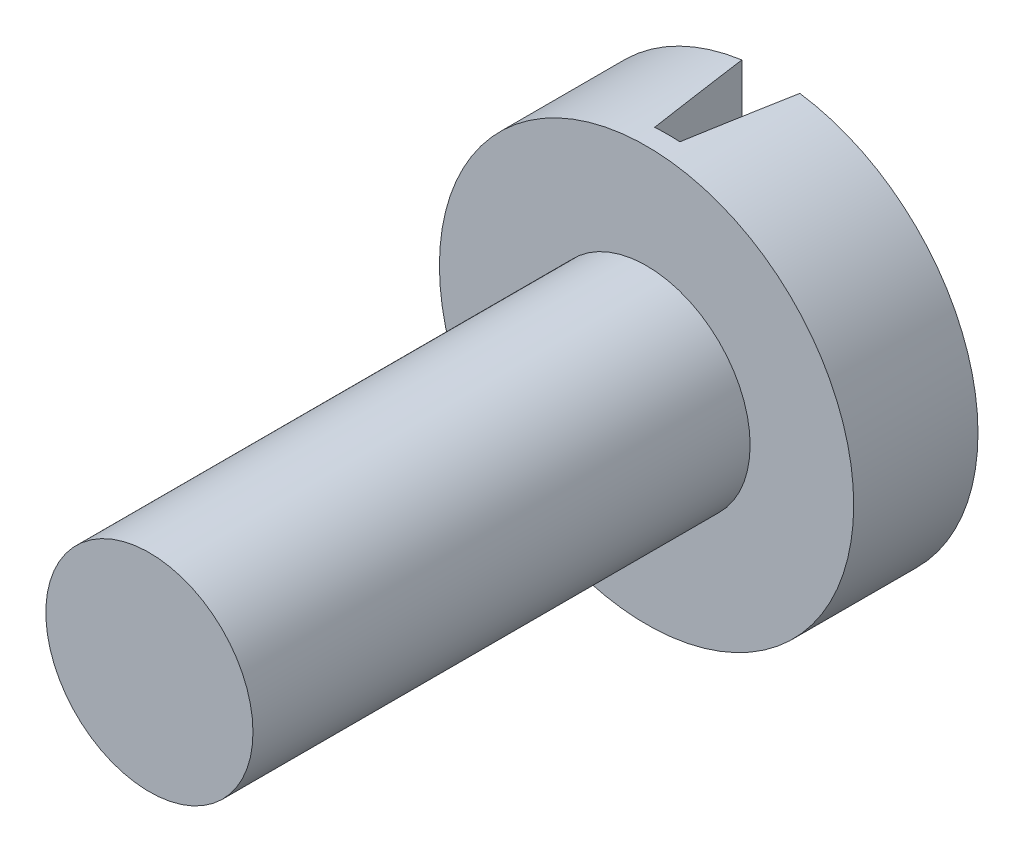
from build123d import *

# Parameters (mm, degrees)
CROQUIS1_R              = 2.5
SALIENTE_EXTRUIR1_DEPTH = 12
CROQUIS2_R              = 5
SALIENTE_EXTRUIR2_DEPTH = 3
CROQUIS3_W              = 1.4
CROQUIS3_H              = 11
CORTAR_EXTRUIR2_DEPTH   = 2.5
CORTAR_EXTRUIR2_TAPER   = 9


with BuildPart() as part:
    # Croquis1 → Saliente-Extruir1 (new body)
    with BuildSketch(Plane.XY):
        Circle(CROQUIS1_R)
    extrude(amount=SALIENTE_EXTRUIR1_DEPTH)

    # Croquis2 → Saliente-Extruir2 (add)
    with BuildSketch(Plane.XY):
        Circle(CROQUIS2_R)
    extrude(amount=-SALIENTE_EXTRUIR2_DEPTH)

    # Croquis3 → Cortar-Extruir2 (cut)
    with BuildSketch(Plane(origin=(0, 0, -3), x_dir=(-1, 0, 0), z_dir=(0, 0, -1))):
        Rectangle(CROQUIS3_W, CROQUIS3_H)
    extrude(amount=-CORTAR_EXTRUIR2_DEPTH, taper=CORTAR_EXTRUIR2_TAPER, mode=Mode.SUBTRACT)


solid = part.part
